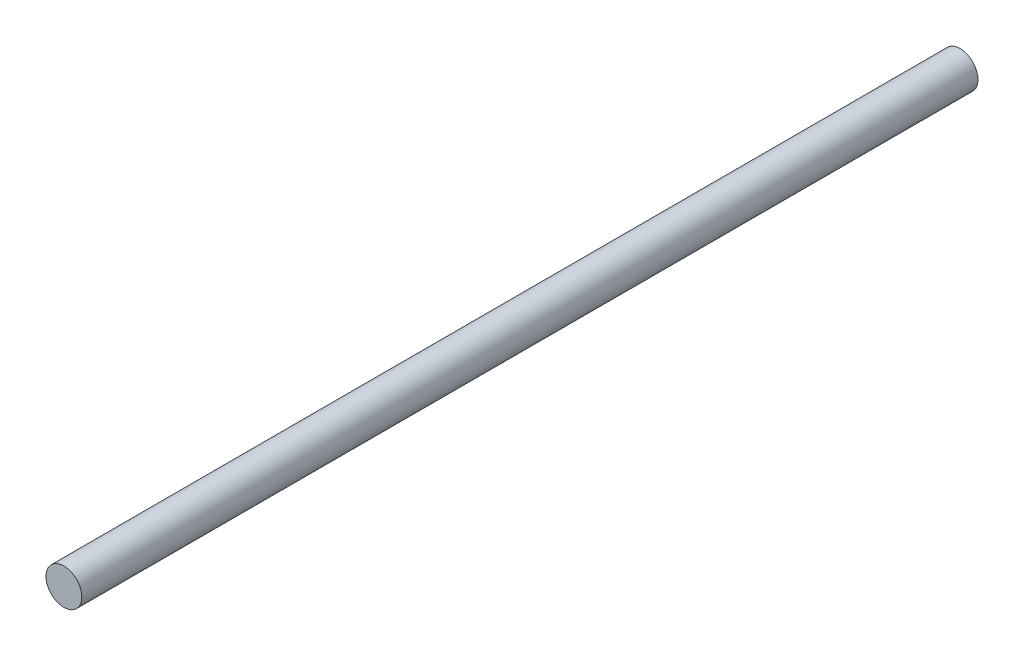
from build123d import *

# Parameters (mm, degrees)
ESBO_O1_R                = 2
RESSALTO_EXTRUS_O1_DEPTH = 100


with BuildPart() as part:
    # Esboço1 → Ressalto-extrusão1 (new body)
    with BuildSketch(Plane.XY):
        Circle(ESBO_O1_R)
    extrude(amount=RESSALTO_EXTRUS_O1_DEPTH)


solid = part.part
